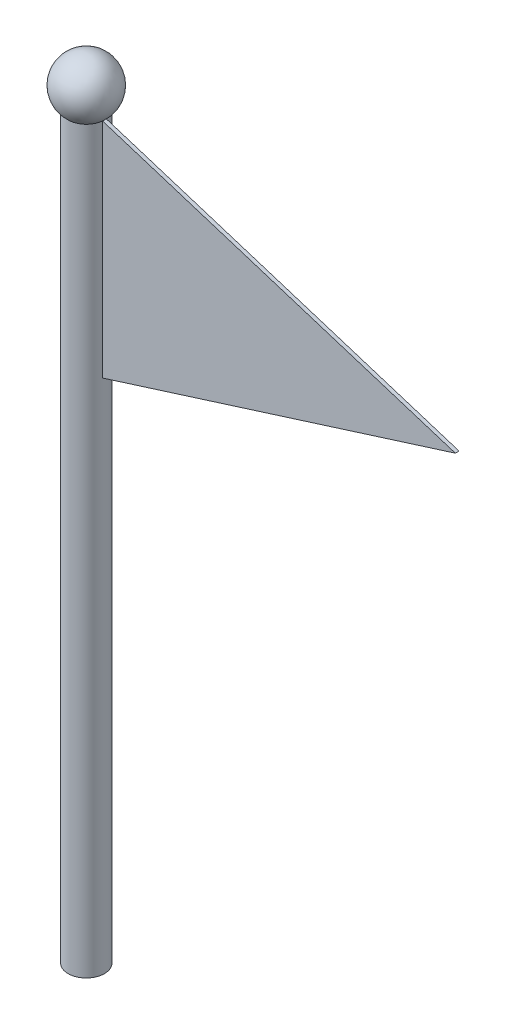
from build123d import *

# Parameters (mm, degrees)
SKETCH1_R           = 24.5
BOSS_EXTRUDE1_DEPTH = 1000
BOSS_EXTRUDE2_DEPTH = 2.5


with BuildPart() as part:
    # Sketch1 → Boss-Extrude1 (new body)
    with BuildSketch(Plane(origin=(0, 0, 0), x_dir=(1, 0, 0), z_dir=(0, 1, 0))):
        Circle(SKETCH1_R)
    extrude(amount=BOSS_EXTRUDE1_DEPTH)

    # Sketch2 → Revolve5 (revolve)
    with BuildSketch(Plane.XY):
        with BuildLine():
            Line((0, 1062.5), (0, 987.5))
            ThreePointArc((0, 987.5), (37.5, 1025), (0, 1062.5))
        make_face()
    revolve(axis=Axis((0, 1062.5, 0), (0, -1, 0)))

    # Sketch3 → Boss-Extrude2 (add, symmetric)
    with BuildSketch(Plane.XY):
        Polygon((24.5, 996.609860867), (500, 846.609860867), (24.5, 696.609860867), (0, 696.609860867), (0, 996.609860867), align=None)
    extrude(amount=BOSS_EXTRUDE2_DEPTH, both=True)


solid = part.part
